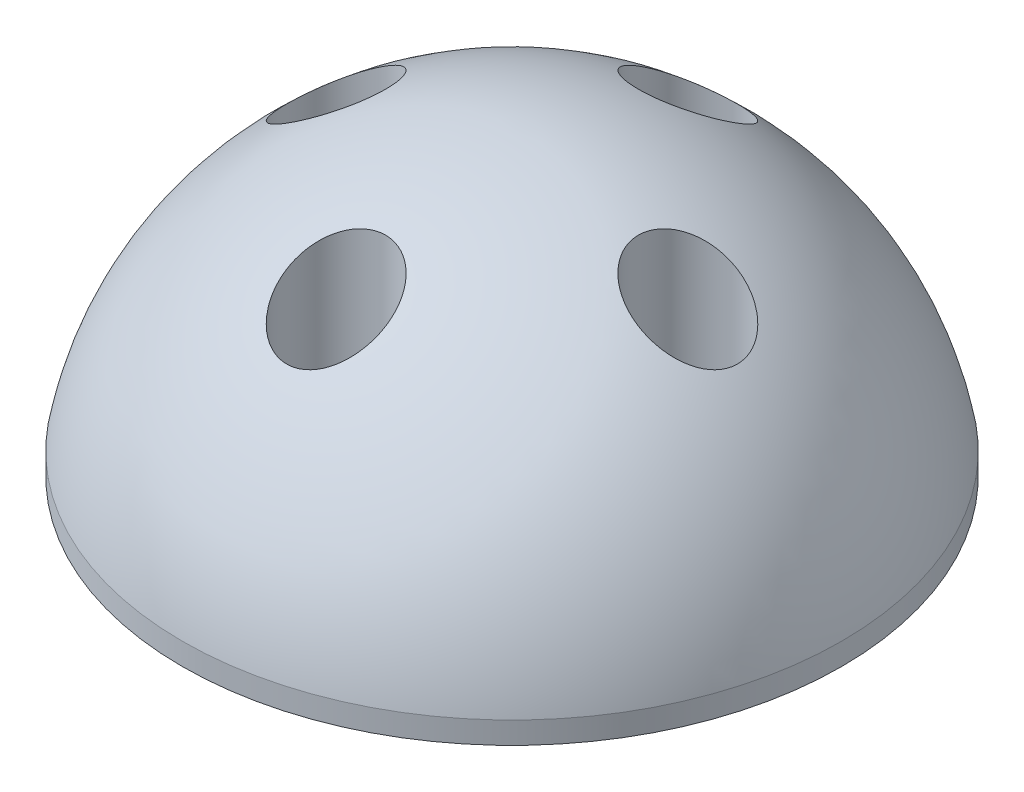
from build123d import *

# Parameters (mm, degrees)
SKETCH1_R               = 15
BOSS_EXTRUDE1_DEPTH     = 1
CUT_EXTRUDE1_REACH      = 27.145
CUT_EXTRUDE1_END_RADIUS = 15.25
SKETCH3_R               = 1.375
CIRPATTERN1_COUNT       = 4
CUT_EXTRUDE2_REACH      = 27.645
CUT_EXTRUDE2_END_RADIUS = 15.25
CUT_EXTRUDE2_START      = -0.5
SKETCH8_R               = 2.25
CIRPATTERN2_COUNT       = 4


with BuildPart() as part:
    # Sketch1 → Boss-Extrude1 (new body)
    with BuildSketch(Plane(origin=(0, 0, 0), x_dir=(1, 0, 0), z_dir=(0, 1, 0))):
        with Locations(Location((0, 0, 0), (0, 0, 270))):
            Circle(SKETCH1_R)
    extrude(amount=BOSS_EXTRUDE1_DEPTH)

    # Sketch2 → Revolve1 (revolve)
    with BuildSketch(Plane.XY, mode=Mode.PRIVATE) as revolve1_sk:
        with BuildLine():
            Line((0, 1), (-15, 1))
            ThreePointArc((-15, 1), (-9.762812095, 9.965374514), (0, 13.5))
            Line((0, 13.5), (0, 1))
        make_face()
    revolve(revolve1_sk.sketch.rotate(Axis((0, 1, 0), (0, 1, 0)), 180), axis=Axis((0, 1, 0), (0, 1, 0)))

    # Cut-Extrude1: up to this sphere (the profile starts inside it)
    cut_extrude1_end = Location((0, -1.75, 0)) * Sphere(CUT_EXTRUDE1_END_RADIUS, mode=Mode.PRIVATE)
    # Sketch3 → Cut-Extrude1 (cut, up to the surface)
    with BuildSketch(Plane.XZ, mode=Mode.PRIVATE) as cut_extrude1_sk1:
        with Locations(Location((0, 8, 0), (0, 0, 270))):
            Circle(SKETCH3_R)
    cut_extrude1_tool1 = extrude(cut_extrude1_sk1.sketch, amount=-CUT_EXTRUDE1_REACH, mode=Mode.PRIVATE) & cut_extrude1_end
    cut_extrude1 = cut_extrude1_tool1.solids().sort_by_distance((0, 0, 8))[0]
    add(cut_extrude1, mode=Mode.SUBTRACT)

    # CirPattern1: Cut-Extrude1 ×4 about axis
    cirpattern1_axis = Axis((0, 0, 0), (0, 1, 0))
    for i in range(1, CIRPATTERN1_COUNT):
        add(cut_extrude1.rotate(cirpattern1_axis, i * 360 / CIRPATTERN1_COUNT), mode=Mode.SUBTRACT)

    # Cut-Extrude2: up to this sphere (the profile starts inside it)
    cut_extrude2_end = Location((0, -1.75, 0)) * Sphere(CUT_EXTRUDE2_END_RADIUS, mode=Mode.PRIVATE)
    # Sketch8 → Cut-Extrude2 (cut, up to the surface)
    with BuildSketch(Plane.XZ.offset(CUT_EXTRUDE2_START), mode=Mode.PRIVATE) as cut_extrude2_sk1:
        with Locations(Location((-8, 0, 0), (0, 0, 270))):
            Circle(SKETCH8_R)
    cut_extrude2_tool1 = extrude(cut_extrude2_sk1.sketch, amount=-CUT_EXTRUDE2_REACH, mode=Mode.PRIVATE) & cut_extrude2_end
    cut_extrude2 = cut_extrude2_tool1.solids().sort_by_distance((-8, 0.5, 0))[0]
    add(cut_extrude2, mode=Mode.SUBTRACT)

    # CirPattern2: Cut-Extrude2 ×4 about axis
    cirpattern2_axis = Axis((0, 0, 0), (0, 1, 0))
    for i in range(1, CIRPATTERN2_COUNT):
        add(cut_extrude2.rotate(cirpattern2_axis, i * 360 / CIRPATTERN2_COUNT), mode=Mode.SUBTRACT)


solid = part.part
